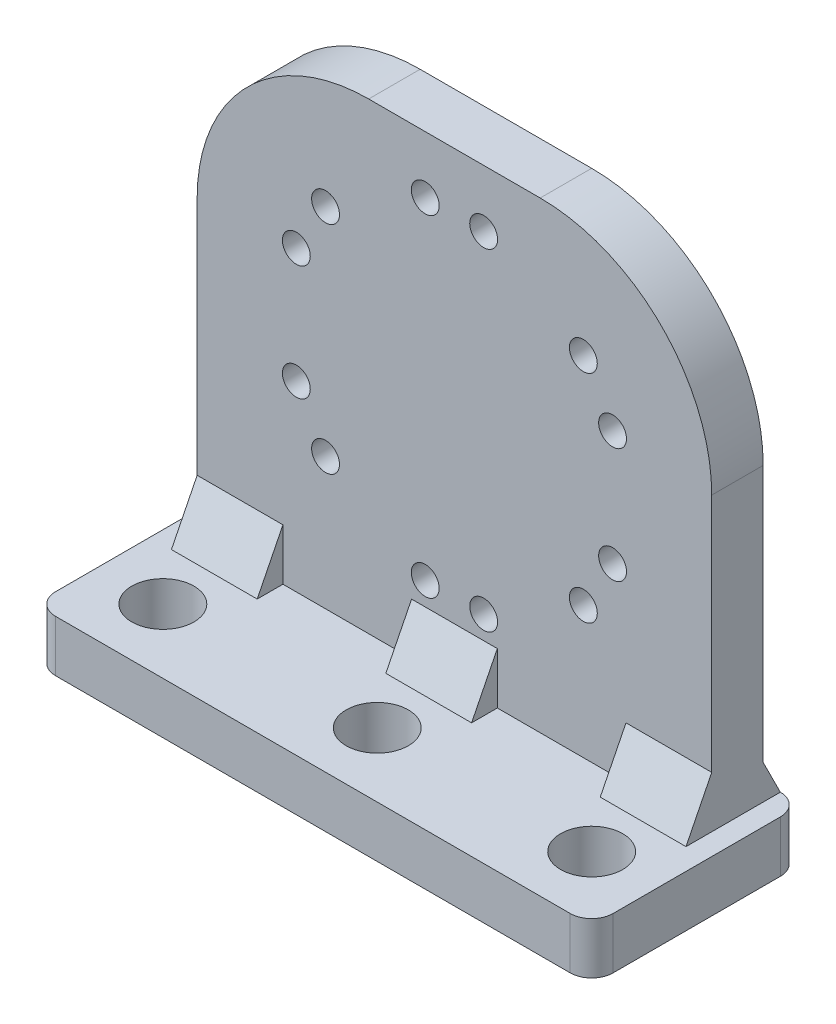
from build123d import *

# Parameters (mm, degrees)
SKETCH1_W           = 60
SKETCH1_H           = 60
BOSS_EXTRUDE1_DEPTH = 6
SKETCH2_W           = 10
SKETCH2_H           = 6
BOSS_EXTRUDE2_DEPTH = 14
BOSS_EXTRUDE3_DEPTH = 10
SKETCH4_R           = 3.625
CUT_EXTRUDE1_DEPTH  = 15
LPATTERN2_COUNT     = 3
LPATTERN2_PITCH     = 25
SKETCH5_R           = 1.625
CUT_EXTRUDE2_DEPTH  = 15
CIRPATTERN2_COUNT   = 6
FILLET1_R           = 20
SKETCH_3_W          = 65
SKETCH_3_H          = 40
SKETCH_3_R          = 3.625
EXTRUDE_1_DEPTH     = 6
SKETCH_6_W          = 15.5
SKETCH_6_H          = 6
CUT_EXTRUDE_2_DEPTH = 65
FILLET_2_R          = 2.5
SKETCH_7_W          = 2
SKETCH_7_H          = 4
CUT_EXTRUDE_3_DEPTH = 10


with BuildPart() as part:
    # Sketch1 → Boss-Extrude1 (new body)
    with BuildSketch(Plane.XY):
        Rectangle(SKETCH1_W, SKETCH1_H)
    extrude(amount=BOSS_EXTRUDE1_DEPTH)

    # Sketch2 → Boss-Extrude2 (add)
    with BuildSketch(Plane.XY.offset(6)):
        with Locations((25, -27)):
            Rectangle(SKETCH2_W, SKETCH2_H)
    boss_extrude2 = extrude(amount=BOSS_EXTRUDE2_DEPTH)

    # Sketch3 → Boss-Extrude3 (add)
    with BuildSketch(Plane(origin=(30, 0, 0), x_dir=(0, 0, -1), z_dir=(1, 0, 0))):
        Polygon((-6, -18), (-9, -24), (-6, -24), align=None)
        Polygon((0, -20), (2, -24), (0, -24), align=None)
    boss_extrude3 = extrude(amount=-BOSS_EXTRUDE3_DEPTH)

    # Sketch4 → Cut-Extrude1 (cut)
    with BuildSketch(Plane(origin=(0, -24, 0), x_dir=(1, 0, 0), z_dir=(0, 1, 0))):
        with Locations((25, -15)):
            Circle(SKETCH4_R)
    cut_extrude1 = extrude(amount=-CUT_EXTRUDE1_DEPTH, mode=Mode.SUBTRACT)

    # LPattern2: Boss-Extrude2, Boss-Extrude3, Cut-Extrude1 ×3
    with Locations(*[(-i * LPATTERN2_PITCH, 0, 0) for i in range(1, LPATTERN2_COUNT)]):
        add(boss_extrude2)
        add(boss_extrude3)
        add(cut_extrude1, mode=Mode.SUBTRACT)

    # Sketch5 → Cut-Extrude2 (cut)
    with BuildSketch(Plane(origin=(0, 0, 0), x_dir=(-1, 0, 0), z_dir=(0, 0, -1))):
        with Locations((3.406977246, 23.321928114)):
            Circle(SKETCH5_R)
        with Locations((-3.406977246, 23.321928114)):
            Circle(SKETCH5_R)
    cut_extrude2 = extrude(amount=-CUT_EXTRUDE2_DEPTH, mode=Mode.SUBTRACT)

    # CirPattern2: Cut-Extrude2 ×6 about axis
    cirpattern2_axis = Axis((0, 4, 0), (0, 0, 1))
    for i in range(1, CIRPATTERN2_COUNT):
        add(cut_extrude2.rotate(cirpattern2_axis, i * 360 / CIRPATTERN2_COUNT), mode=Mode.SUBTRACT)

    # Fillet1
    fillet1_edges = [part.edges().sort_by_distance(p)[0] for p in [
        (-30, 30, 3),
        (30, 30, 3),
    ]]
    fillet(fillet1_edges, radius=FILLET1_R)

    # 스케치3 → 보스-돌출1 (add)
    with BuildSketch(Plane.XZ.offset(30)):
        with Locations((0, 2.5)):
            Rectangle(SKETCH_3_W, SKETCH_3_H)
        with Locations((-25, 15)):
            Circle(SKETCH_3_R, mode=Mode.SUBTRACT)
        with Locations((0, 15)):
            Circle(SKETCH_3_R, mode=Mode.SUBTRACT)
        with Locations((25, 15)):
            Circle(SKETCH_3_R, mode=Mode.SUBTRACT)
        with Locations((-25, -10)):
            Circle(SKETCH_3_R, mode=Mode.SUBTRACT)
        with Locations((0, -10)):
            Circle(SKETCH_3_R, mode=Mode.SUBTRACT)
        with Locations((25, -10)):
            Circle(SKETCH_3_R, mode=Mode.SUBTRACT)
    extrude(amount=-EXTRUDE_1_DEPTH)

    # 스케치6 → 컷-돌출2 (cut)
    with BuildSketch(Plane(origin=(32.5, 0, 0), x_dir=(0, 0, -1), z_dir=(1, 0, 0))):
        with Locations((9.75, -27)):
            Rectangle(SKETCH_6_W, SKETCH_6_H)
    extrude(amount=-CUT_EXTRUDE_2_DEPTH, mode=Mode.SUBTRACT)

    # 필렛2
    fillet_2_edges = [part.edges().sort_by_distance(p)[0] for p in [
        (-32.5, -27, 22.5),
        (-32.5, -27, -2),
        (32.5, -27, 22.5),
        (32.5, -27, -2),
    ]]
    fillet(fillet_2_edges, radius=FILLET_2_R)

    # 스케치7 → 컷-돌출3 (cut)
    with BuildSketch(Plane(origin=(5, 0, 0), x_dir=(0, 0, -1), z_dir=(1, 0, 0))):
        with Locations((1, -22)):
            Rectangle(SKETCH_7_W, SKETCH_7_H)
    extrude(amount=-CUT_EXTRUDE_3_DEPTH, mode=Mode.SUBTRACT)


solid = part.part
